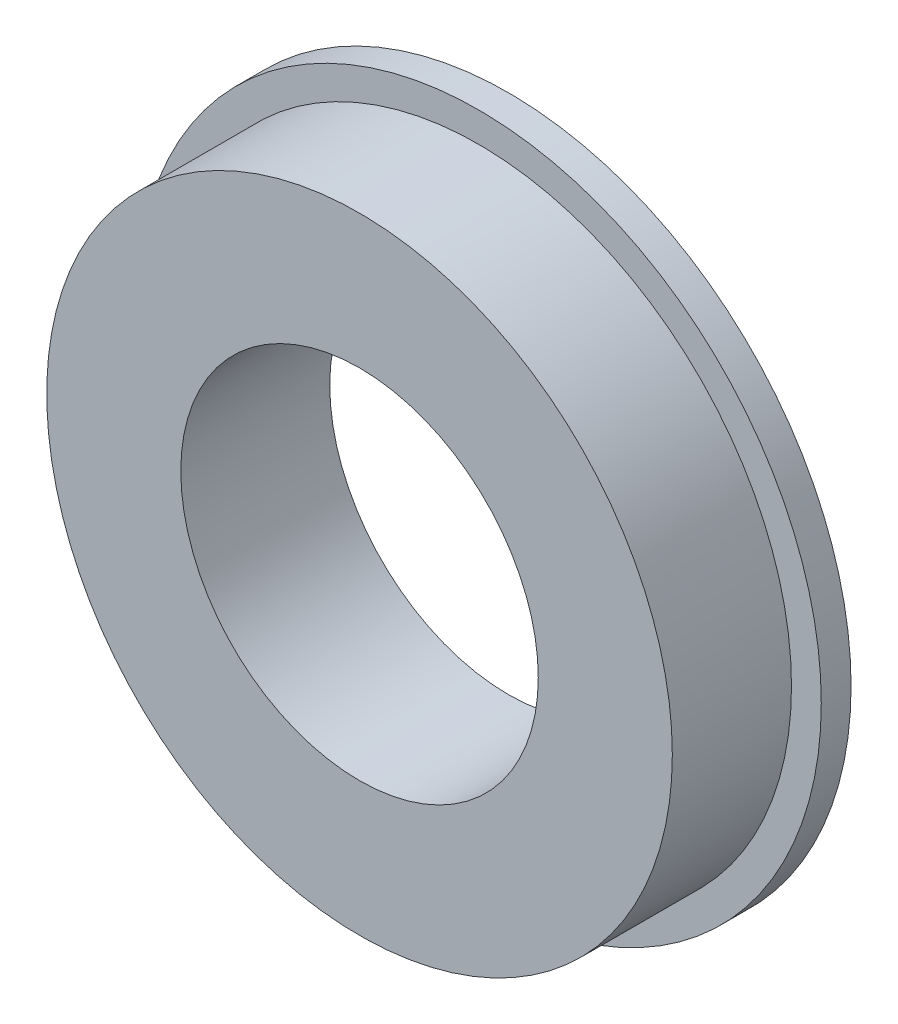
from build123d import *

# Parameters (mm, degrees)
SKETCH_1_R          = 11.5
EXTRUDE_1_DEPTH     = 1
SKETCH_2_R          = 10.5
EXTRUDE_2_DEPTH     = 4
SKETCH_3_R          = 6
CUT_EXTRUDE_1_DEPTH = 6


with BuildPart() as part:
    # 草图1 → 凸台-拉伸1 (new body)
    with BuildSketch(Plane.XY):
        Circle(SKETCH_1_R)
    extrude(amount=EXTRUDE_1_DEPTH)

    # 草图2 → 凸台-拉伸2 (add)
    with BuildSketch(Plane.XY.offset(1)):
        Circle(SKETCH_2_R)
    extrude(amount=EXTRUDE_2_DEPTH)

    # 草图3 → 切除-拉伸1 (cut, through all)
    with BuildSketch(Plane.XY.offset(5)):
        Circle(SKETCH_3_R)
    extrude(amount=-CUT_EXTRUDE_1_DEPTH, mode=Mode.SUBTRACT)


solid = part.part
